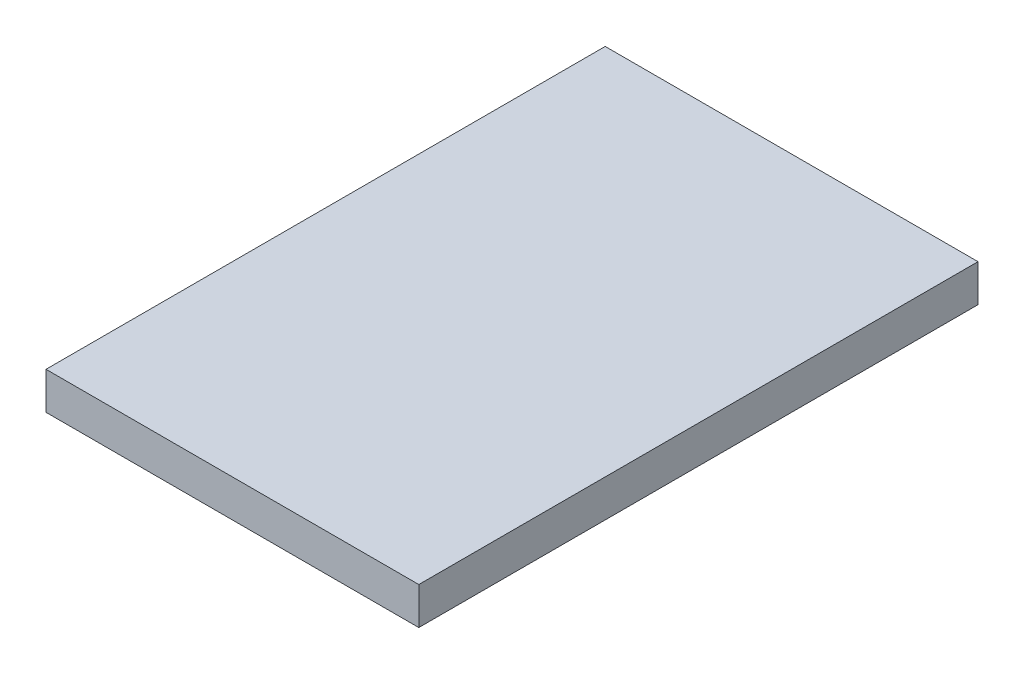
from build123d import *

# Parameters (mm, degrees)
SKETCH2_W           = 10
SKETCH2_H           = 15
BOSS_EXTRUDE1_DEPTH = 1


with BuildPart() as part:
    # Sketch2 → Boss-Extrude1 (new body)
    with BuildSketch(Plane(origin=(0, 0, 0), x_dir=(1, 0, 0), z_dir=(0, 1, 0))):
        Rectangle(SKETCH2_W, SKETCH2_H)
    extrude(amount=BOSS_EXTRUDE1_DEPTH)


solid = part.part
